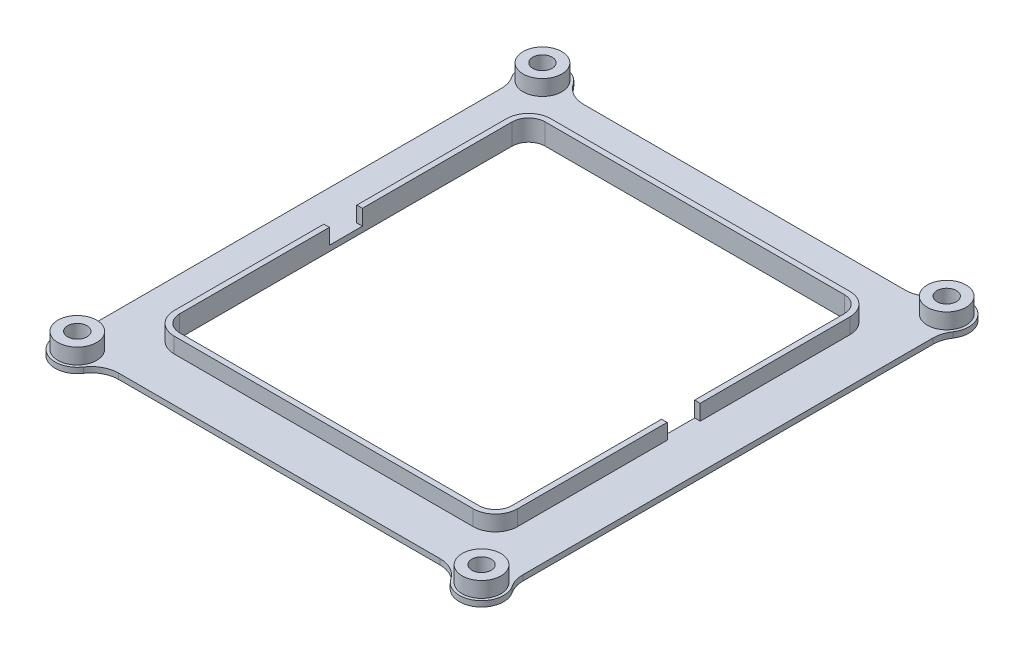
from build123d import *
from build123d.topology import SkipClean

# Parameters (mm, degrees)
FRAMEANDBOLTHOLES_DEPTH       = 3.8
INSIDEFILLET_DEPTH            = 3.8
MIRRORFILLET2_COPY_1_DEPTH    = 3.8
WIRETROUGH_DEPTH              = 1
WIREINSIDEWALL_DEPTH          = 2.8
WIRESPACEMIRROR2_COPY_1_DEPTH = 1
WIRESPACEMIRROR2_COPY_2_DEPTH = 2.8
INNERRING_START               = 1
INNERRING_DEPTH               = 1
REMOVEOUTERRING_START         = -2.8
SKETCH8_W                     = 100
SKETCH8_H                     = 100
SKETCH8_R                     = 3.5
SKETCH8_W_2                   = 62
SKETCH8_H_2                   = 68
REMOVEOUTERRING_DEPTH         = 2.8
BOSS_EXTRUDE2_DEPTH           = 1
MIRROR2_COPY_1_DEPTH          = 1
SKETCH10_W                    = 2.5
SKETCH10_H                    = 78.428011258
SKETCH10_H_2                  = 79.101020514
BOSS_EXTRUDE3_DEPTH           = 1
FILLET1_R                     = 5
SKETCH11_R                    = 3
CUT_EXTRUDE1_DEPTH            = 2.8


with BuildPart() as part:
    # Sketch1 → FrameAndBoltHoles (new body)
    with BuildSketch(Plane(origin=(0, 0, 0), x_dir=(1, 0, 0), z_dir=(0, 1, 0))):
        with BuildLine():
            Line((33, 42), (-33, 42))
            ThreePointArc((-33, 42), (-33.036666571, 41.494706462), (-33.145898034, 41))
            Line((-33.145898034, 41), (33.145898034, 41))
            ThreePointArc((33.145898034, 41), (33.036666571, 41.494706462), (33, 42))
        make_face()
        with BuildLine():
            ThreePointArc((-33.145898034, 41), (-33.036666571, 41.494706462), (-33, 42))
            ThreePointArc((-33, 42), (-38.974873734, 44.474873734), (-36.5, 38.5))
            ThreePointArc((-36.5, 38.5), (-35.994706462, 38.536666571), (-35.5, 38.645898034))
            Line((-35.5, 38.645898034), (-35.5, 40.563859338))
            ThreePointArc((-35.5, 40.563859338), (-38.051209206, 42.810092587), (-34.75, 42))
            ThreePointArc((-34.75, 42), (-34.83030749, 41.475951413), (-35.063859338, 41))
            Line((-35.063859338, 41), (-33.145898034, 41))
        make_face()
        with BuildLine():
            ThreePointArc((-35.5, 38.645898034), (-34.025126266, 39.525126266), (-33.145898034, 41))
            Line((-33.145898034, 41), (-35.063859338, 41))
            ThreePointArc((-35.063859338, 41), (-35.262563133, 40.762563133), (-35.5, 40.563859338))
            Line((-35.5, 40.563859338), (-35.5, 38.645898034))
        make_face()
        with BuildLine():
            ThreePointArc((-35.5, 38.645898034), (-35.994706462, 38.536666571), (-36.5, 38.5))
            Line((-36.5, 38.5), (-36.5, -38.5))
            ThreePointArc((-36.5, -38.5), (-35.994706462, -38.536666571), (-35.5, -38.645898034))
            Line((-35.5, -38.645898034), (-35.5, 38.645898034))
        make_face()
        with BuildLine():
            ThreePointArc((-35.5, -38.645898034), (-35.994706462, -38.536666571), (-36.5, -38.5))
            ThreePointArc((-36.5, -38.5), (-38.974873734, -44.474873734), (-33, -42))
            ThreePointArc((-33, -42), (-33.036666571, -41.494706462), (-33.145898034, -41))
            Line((-33.145898034, -41), (-35.063859338, -41))
            ThreePointArc((-35.063859338, -41), (-34.83030749, -41.475951413), (-34.75, -42))
            ThreePointArc((-34.75, -42), (-38.051209206, -42.810092587), (-35.5, -40.563859338))
            Line((-35.5, -40.563859338), (-35.5, -38.645898034))
        make_face()
        with BuildLine():
            ThreePointArc((-33.145898034, -41), (-34.025126266, -39.525126266), (-35.5, -38.645898034))
            Line((-35.5, -38.645898034), (-35.5, -40.563859338))
            ThreePointArc((-35.5, -40.563859338), (-35.262563133, -40.762563133), (-35.063859338, -41))
            Line((-35.063859338, -41), (-33.145898034, -41))
        make_face()
        with BuildLine():
            ThreePointArc((-33.145898034, -41), (-33.036666571, -41.494706462), (-33, -42))
            Line((-33, -42), (33, -42))
            ThreePointArc((33, -42), (33.036666571, -41.494706462), (33.145898034, -41))
            Line((33.145898034, -41), (-33.145898034, -41))
        make_face()
        with BuildLine():
            ThreePointArc((40, -42), (38.974873734, -39.525126266), (36.5, -38.5))
            ThreePointArc((36.5, -38.5), (35.994706462, -38.536666571), (35.5, -38.645898034))
            Line((35.5, -38.645898034), (35.5, -40.563859338))
            ThreePointArc((35.5, -40.563859338), (37.310092587, -40.448790794), (38.25, -42))
            ThreePointArc((38.25, -42), (35.975951413, -43.66969251), (35.063859338, -41))
            Line((35.063859338, -41), (33.145898034, -41))
            ThreePointArc((33.145898034, -41), (33.036666571, -41.494706462), (33, -42))
            ThreePointArc((33, -42), (36.5, -45.5), (40, -42))
        make_face()
        with BuildLine():
            Line((35.5, -40.563859338), (35.5, -38.645898034))
            ThreePointArc((35.5, -38.645898034), (34.025126266, -39.525126266), (33.145898034, -41))
            Line((33.145898034, -41), (35.063859338, -41))
            ThreePointArc((35.063859338, -41), (35.262563133, -40.762563133), (35.5, -40.563859338))
        make_face()
        with BuildLine():
            Line((36.5, -38.5), (36.5, 38.5))
            ThreePointArc((36.5, 38.5), (35.994706462, 38.536666571), (35.5, 38.645898034))
            Line((35.5, 38.645898034), (35.5, -38.645898034))
            ThreePointArc((35.5, -38.645898034), (35.994706462, -38.536666571), (36.5, -38.5))
        make_face()
        with BuildLine():
            ThreePointArc((40, 42), (36.5, 45.5), (33, 42))
            ThreePointArc((33, 42), (33.036666571, 41.494706462), (33.145898034, 41))
            Line((33.145898034, 41), (35.063859338, 41))
            ThreePointArc((35.063859338, 41), (35.975951413, 43.66969251), (38.25, 42))
            ThreePointArc((38.25, 42), (37.310092587, 40.448790794), (35.5, 40.563859338))
            Line((35.5, 40.563859338), (35.5, 38.645898034))
            ThreePointArc((35.5, 38.645898034), (35.994706462, 38.536666571), (36.5, 38.5))
            ThreePointArc((36.5, 38.5), (38.974873734, 39.525126266), (40, 42))
        make_face()
        with BuildLine():
            Line((35.063859338, 41), (33.145898034, 41))
            ThreePointArc((33.145898034, 41), (34.025126266, 39.525126266), (35.5, 38.645898034))
            Line((35.5, 38.645898034), (35.5, 40.563859338))
            ThreePointArc((35.5, 40.563859338), (35.262563133, 40.762563133), (35.063859338, 41))
        make_face()
    extrude(amount=FRAMEANDBOLTHOLES_DEPTH)

    # Sketch2 → InsideFillet (add)
    with BuildSketch(Plane(origin=(0, 0, 0), x_dir=(1, 0, 0), z_dir=(0, 1, 0))):
        with BuildLine():
            Line((-35.5, 38.645898034), (-35.5, 36.500000047))
            ThreePointArc((-35.5, 36.500000047), (-35.313532909, 37.781964835), (-34.769584986, 38.957687741))
            ThreePointArc((-34.769584986, 38.957687741), (-35.125920402, 38.781008658), (-35.5, 38.645898034))
        make_face()
    insidefillet = extrude(amount=INSIDEFILLET_DEPTH)

    # MirrorFillet: InsideFillet across plane
    add(insidefillet.mirror(Plane(origin=(0, 0, 0), x_dir=(0, 0, 1), z_dir=(1, 0, 0))))

    # MirrorFillet2: InsideFillet across plane
    add(insidefillet.mirror(Plane.XY))

    # MirrorFillet2 copy 1 sketch → MirrorFillet2 copy 1 (add)
    with BuildSketch(Plane(origin=(0, 0, 0), x_dir=(-1, 0, 0), z_dir=(0, 1, 0))):
        with BuildLine():
            Line((-35.5, 38.645898034), (-35.5, 36.500000047))
            ThreePointArc((-35.5, 36.500000047), (-35.313532909, 37.781964835), (-34.769584986, 38.957687741))
            ThreePointArc((-34.769584986, 38.957687741), (-35.125920402, 38.781008658), (-35.5, 38.645898034))
        make_face()
    extrude(amount=MIRRORFILLET2_COPY_1_DEPTH)

    # Sketch3 → WireTrough (add)
    with BuildSketch(Plane(origin=(0, 0, 0), x_dir=(1, 0, 0), z_dir=(0, 1, 0))):
        with BuildLine():
            Line((-27, 41), (-27, 34))
            ThreePointArc((-27, 34), (-26.54814994, 33.974397001), (-26.102084238, 33.897915762))
            Line((-26.102084238, 33.897915762), (-19, 41))
            Line((-19, 41), (-27, 41))
        make_face()
        with BuildLine():
            ThreePointArc((-31, 30), (-29.828427125, 32.828427125), (-27, 34))
            Line((-27, 34), (-27, 41))
            Line((-27, 41), (-31, 41))
            ThreePointArc((-31, 41), (-34.181980515, 39.681980515), (-35.5, 36.5))
            Line((-35.5, 36.5), (-35.5, 30))
            Line((-35.5, 30), (-31, 30))
        make_face()
        with BuildLine():
            ThreePointArc((-30.897915762, 29.102084238), (-30.974397001, 29.54814994), (-31, 30))
            Line((-31, 30), (-35.5, 30))
            Line((-35.5, 30), (-35.5, 24.5))
            Line((-35.5, 24.5), (-30.897915762, 29.102084238))
        make_face()
        with BuildLine():
            Line((-27, 34), (-27, 33))
            Line((-27, 33), (-26.102084238, 33.897915762))
            ThreePointArc((-26.102084238, 33.897915762), (-26.54814994, 33.974397001), (-27, 34))
        make_face()
        with BuildLine():
            ThreePointArc((-30, 30), (-29.121320344, 32.121320344), (-27, 33))
            Line((-27, 33), (-27, 34))
            ThreePointArc((-27, 34), (-29.828427125, 32.828427125), (-31, 30))
            Line((-31, 30), (-30, 30))
        make_face()
        with BuildLine():
            Line((-30.897915762, 29.102084238), (-30, 30))
            Line((-30, 30), (-31, 30))
            ThreePointArc((-31, 30), (-30.974397001, 29.54814994), (-30.897915762, 29.102084238))
        make_face()
    wiretrough = extrude(amount=WIRETROUGH_DEPTH)

    # Sketch4 → WireInsideWall (add)
    with BuildSketch(Plane(origin=(0, 1, 0), x_dir=(1, 0, 0), z_dir=(0, 1, 0))):
        with BuildLine():
            ThreePointArc((-30, 30), (-29.121320344, 32.121320344), (-27, 33))
            Line((-27, 33), (-26.102084238, 33.897915762))
            ThreePointArc((-26.102084238, 33.897915762), (-26.54814994, 33.974397001), (-27, 34))
            ThreePointArc((-27, 34), (-29.828427125, 32.828427125), (-31, 30))
            ThreePointArc((-31, 30), (-30.974397001, 29.54814994), (-30.897915762, 29.102084238))
            Line((-30.897915762, 29.102084238), (-30, 30))
        make_face()
        with BuildLine():
            Line((-26, 34), (-26.102084238, 33.897915762))
            ThreePointArc((-26.102084238, 33.897915762), (-25.172171436, 33.557954854), (-24.354248689, 33))
            Line((-24.354248689, 33), (0, 33))
            Line((0, 33), (0, 34))
            Line((0, 34), (-26, 34))
        make_face()
        with BuildLine():
            Line((-26.102084238, 33.897915762), (-27, 33))
            Line((-27, 33), (-24.354248689, 33))
            ThreePointArc((-24.354248689, 33), (-25.172171436, 33.557954854), (-26.102084238, 33.897915762))
        make_face()
        with BuildLine():
            Line((-30, 27.354248689), (-30, 30))
            Line((-30, 30), (-30.897915762, 29.102084238))
            ThreePointArc((-30.897915762, 29.102084238), (-30.557954854, 28.172171436), (-30, 27.354248689))
        make_face()
        with BuildLine():
            ThreePointArc((-30, 27.354248689), (-30.557954854, 28.172171436), (-30.897915762, 29.102084238))
            Line((-30.897915762, 29.102084238), (-31, 29))
            Line((-31, 29), (-31, 0))
            Line((-31, 0), (-30, 0))
            Line((-30, 0), (-30, 27.354248689))
        make_face()
        with BuildLine():
            ThreePointArc((-27, 34), (-26.54814994, 33.974397001), (-26.102084238, 33.897915762))
            Line((-26.102084238, 33.897915762), (-26, 34))
            Line((-26, 34), (-27, 34))
        make_face()
        with BuildLine():
            Line((-31, 29), (-30.897915762, 29.102084238))
            ThreePointArc((-30.897915762, 29.102084238), (-30.974397001, 29.54814994), (-31, 30))
            Line((-31, 30), (-31, 29))
        make_face()
    wireinsidewall = extrude(amount=WIREINSIDEWALL_DEPTH)

    # WireSpaceMirror: WireTrough, WireInsideWall across plane
    add(wiretrough.mirror(Plane(origin=(0, 0, 0), x_dir=(0, 0, 1), z_dir=(1, 0, 0))))
    add(wireinsidewall.mirror(Plane(origin=(0, 0, 0), x_dir=(0, 0, 1), z_dir=(1, 0, 0))))

    # WireSpaceMirror2: WireTrough, WireInsideWall across plane
    add(wiretrough.mirror(Plane.XY))
    add(wireinsidewall.mirror(Plane.XY))

    # WireSpaceMirror2 copy 1 sketch → WireSpaceMirror2 copy 1 (add)
    with BuildSketch(Plane(origin=(0, 0, 0), x_dir=(-1, 0, 0), z_dir=(0, 1, 0))):
        with BuildLine():
            Line((-27, 41), (-27, 34))
            ThreePointArc((-27, 34), (-26.54814994, 33.974397001), (-26.102084238, 33.897915762))
            Line((-26.102084238, 33.897915762), (-19, 41))
            Line((-19, 41), (-27, 41))
        make_face()
        with BuildLine():
            ThreePointArc((-31, 30), (-29.828427125, 32.828427125), (-27, 34))
            Line((-27, 34), (-27, 41))
            Line((-27, 41), (-31, 41))
            ThreePointArc((-31, 41), (-34.181980515, 39.681980515), (-35.5, 36.5))
            Line((-35.5, 36.5), (-35.5, 30))
            Line((-35.5, 30), (-31, 30))
        make_face()
        with BuildLine():
            ThreePointArc((-30.897915762, 29.102084238), (-30.974397001, 29.54814994), (-31, 30))
            Line((-31, 30), (-35.5, 30))
            Line((-35.5, 30), (-35.5, 24.5))
            Line((-35.5, 24.5), (-30.897915762, 29.102084238))
        make_face()
        with BuildLine():
            Line((-27, 34), (-27, 33))
            Line((-27, 33), (-26.102084238, 33.897915762))
            ThreePointArc((-26.102084238, 33.897915762), (-26.54814994, 33.974397001), (-27, 34))
        make_face()
        with BuildLine():
            ThreePointArc((-30, 30), (-29.121320344, 32.121320344), (-27, 33))
            Line((-27, 33), (-27, 34))
            ThreePointArc((-27, 34), (-29.828427125, 32.828427125), (-31, 30))
            Line((-31, 30), (-30, 30))
        make_face()
        with BuildLine():
            Line((-30.897915762, 29.102084238), (-30, 30))
            Line((-30, 30), (-31, 30))
            ThreePointArc((-31, 30), (-30.974397001, 29.54814994), (-30.897915762, 29.102084238))
        make_face()
    extrude(amount=WIRESPACEMIRROR2_COPY_1_DEPTH)

    # WireSpaceMirror2 copy 2 sketch → WireSpaceMirror2 copy 2 (add)
    with BuildSketch(Plane(origin=(0, 1, 0), x_dir=(-1, 0, 0), z_dir=(0, 1, 0))):
        with BuildLine():
            ThreePointArc((-30, 30), (-29.121320344, 32.121320344), (-27, 33))
            Line((-27, 33), (-26.102084238, 33.897915762))
            ThreePointArc((-26.102084238, 33.897915762), (-26.54814994, 33.974397001), (-27, 34))
            ThreePointArc((-27, 34), (-29.828427125, 32.828427125), (-31, 30))
            ThreePointArc((-31, 30), (-30.974397001, 29.54814994), (-30.897915762, 29.102084238))
            Line((-30.897915762, 29.102084238), (-30, 30))
        make_face()
        with BuildLine():
            Line((-26, 34), (-26.102084238, 33.897915762))
            ThreePointArc((-26.102084238, 33.897915762), (-25.172171436, 33.557954854), (-24.354248689, 33))
            Line((-24.354248689, 33), (0, 33))
            Line((0, 33), (0, 34))
            Line((0, 34), (-26, 34))
        make_face()
        with BuildLine():
            Line((-26.102084238, 33.897915762), (-27, 33))
            Line((-27, 33), (-24.354248689, 33))
            ThreePointArc((-24.354248689, 33), (-25.172171436, 33.557954854), (-26.102084238, 33.897915762))
        make_face()
        with BuildLine():
            Line((-30, 27.354248689), (-30, 30))
            Line((-30, 30), (-30.897915762, 29.102084238))
            ThreePointArc((-30.897915762, 29.102084238), (-30.557954854, 28.172171436), (-30, 27.354248689))
        make_face()
        with BuildLine():
            ThreePointArc((-30, 27.354248689), (-30.557954854, 28.172171436), (-30.897915762, 29.102084238))
            Line((-30.897915762, 29.102084238), (-31, 29))
            Line((-31, 29), (-31, 0))
            Line((-31, 0), (-30, 0))
            Line((-30, 0), (-30, 27.354248689))
        make_face()
        with BuildLine():
            ThreePointArc((-27, 34), (-26.54814994, 33.974397001), (-26.102084238, 33.897915762))
            Line((-26.102084238, 33.897915762), (-26, 34))
            Line((-26, 34), (-27, 34))
        make_face()
        with BuildLine():
            Line((-31, 29), (-30.897915762, 29.102084238))
            ThreePointArc((-30.897915762, 29.102084238), (-30.974397001, 29.54814994), (-31, 30))
            Line((-31, 30), (-31, 29))
        make_face()
    extrude(amount=WIRESPACEMIRROR2_COPY_2_DEPTH)

    # Sketch7 → InnerRing (add)
    # profile 1 of 2: a face of its own
    with SkipClean():  # the faces are left unmerged after this step: merging them gives an invalid solid
        with BuildSketch(Plane.XZ.offset(-1).offset(INNERRING_START)):
            with BuildLine():
                Line((35.063859338, 41), (-35.063859338, 41))
                ThreePointArc((-35.063859338, 41), (-35.262563133, 40.762563133), (-35.5, 40.563859338))
                Line((-35.5, 40.563859338), (-35.5, -40.563859338))
                ThreePointArc((-35.5, -40.563859338), (-35.262563133, -40.762563133), (-35.063859338, -41))
                Line((-35.063859338, -41), (35.063859338, -41))
                ThreePointArc((35.063859338, -41), (35.262563133, -40.762563133), (35.5, -40.563859338))
                Line((35.5, -40.563859338), (35.5, 40.563859338))
                ThreePointArc((35.5, 40.563859338), (35.262563133, 40.762563133), (35.063859338, 41))
            make_face()
            Polygon((-30, -33), (-30, 33), (30, 33), (30, -33), (27, -33), (26, -34), (-26, -34), (-27, -33), align=None, mode=Mode.SUBTRACT)
        # profile 2 of 2: a face of its own
        with BuildSketch(Plane.XZ.offset(-1).offset(INNERRING_START)):
            Polygon((26, -34), (27, -33), (-27, -33), (-26, -34), align=None)
        extrude(amount=-INNERRING_DEPTH)

    # Sketch8 → RemoveOuterRing (cut)
    with SkipClean():  # the faces are left unmerged after this step: merging them gives an invalid solid
        with BuildSketch(Plane(origin=(0, 3.8, 0), x_dir=(1, 0, 0), z_dir=(0, 1, 0)).offset(REMOVEOUTERRING_START)):
            Rectangle(SKETCH8_W, SKETCH8_H)
            with Locations(Location((-36.5, 42, 0), (0, 0, 270))):
                Circle(SKETCH8_R, mode=Mode.SUBTRACT)
            with Locations(Location((36.5, 42, 0), (0, 0, 270))):
                Circle(SKETCH8_R, mode=Mode.SUBTRACT)
            with Locations(Location((36.5, -42, 0), (0, 0, 90))):
                Circle(SKETCH8_R, mode=Mode.SUBTRACT)
            with Locations(Location((-36.5, -42, 0), (0, 0, 90))):
                Circle(SKETCH8_R, mode=Mode.SUBTRACT)
            Rectangle(SKETCH8_W_2, SKETCH8_H_2, mode=Mode.SUBTRACT)
        extrude(amount=REMOVEOUTERRING_DEPTH, mode=Mode.SUBTRACT)

    # Sketch9 → Boss-Extrude2 (add)
    with SkipClean():  # the faces are left unmerged after this step: merging them gives an invalid solid
        with BuildSketch(Plane.XZ):
            with BuildLine():
                ThreePointArc((-36.5, -46), (-33.671572875, -44.828427125), (-32.5, -42))
                Line((-32.5, -42), (-33, -42))
                ThreePointArc((-33, -42), (-38.974873734, -44.474873734), (-36.5, -38.5))
                Line((-36.5, -38.5), (-36.5, -38))
                ThreePointArc((-36.5, -38), (-39.328427125, -39.171572875), (-40.5, -42))
                ThreePointArc((-40.5, -42), (-39.328427125, -44.828427125), (-36.5, -46))
            make_face()
        boss_extrude2 = extrude(amount=-BOSS_EXTRUDE2_DEPTH)

    # Mirror1: Boss-Extrude2 across plane
    with SkipClean():  # the faces are left unmerged after this step: merging them gives an invalid solid
        add(boss_extrude2.mirror(Plane(origin=(0, 0, 0), x_dir=(0, 0, 1), z_dir=(1, 0, 0))))

    # Mirror2: Boss-Extrude2 across plane
    with SkipClean():  # the faces are left unmerged after this step: merging them gives an invalid solid
        add(boss_extrude2.mirror(Plane.XY))

    # Mirror2 copy 1 sketch → Mirror2 copy 1 (add)
    with SkipClean():  # the faces are left unmerged after this step: merging them gives an invalid solid
        with BuildSketch(Plane(origin=(0, 0, 0), x_dir=(-1, 0, 0), z_dir=(0, -1, 0))):
            with BuildLine():
                ThreePointArc((-36.5, -46), (-33.671572875, -44.828427125), (-32.5, -42))
                Line((-32.5, -42), (-33, -42))
                ThreePointArc((-33, -42), (-38.974873734, -44.474873734), (-36.5, -38.5))
                Line((-36.5, -38.5), (-36.5, -38))
                ThreePointArc((-36.5, -38), (-39.328427125, -39.171572875), (-40.5, -42))
                ThreePointArc((-40.5, -42), (-39.328427125, -44.828427125), (-36.5, -46))
            make_face()
        extrude(amount=-MIRROR2_COPY_1_DEPTH)

    # Sketch10 → Boss-Extrude3 (add)
    with SkipClean():  # the faces are left unmerged after this step: merging them gives an invalid solid
        with BuildSketch(Plane(origin=(0, 1, 0), x_dir=(1, 0, 0), z_dir=(0, 1, 0))):
            with Locations((37.75, 0.336504628)):
                Rectangle(SKETCH10_W, SKETCH10_H)
            with Locations((-37.75, 0)):
                Rectangle(SKETCH10_W, SKETCH10_H_2)
        extrude(amount=-BOSS_EXTRUDE3_DEPTH)

    # Fillet1
    fillet1_edges = [part.edges().sort_by_distance(p)[0] for p in [
        (-32.5, 0.5, -42),
        (32.5, 0.5, -42),
        (32.5, 0.5, 42),
        (-32.5, 0.5, 42),
        (39, 0.5, -38.877501001),
        (39, 0.5, 38.877501001),
        (-39, 0.5, 38.877501001),
        (-39, 0.5, -38.877501001),
    ]]
    fillet(fillet1_edges, radius=FILLET1_R)

    # Sketch11 → Cut-Extrude1 (cut)
    with SkipClean():  # the faces are left unmerged after this step: merging them gives an invalid solid
        with BuildSketch(Plane(origin=(0, 3.8, 0), x_dir=(1, 0, 0), z_dir=(0, 1, 0))):
            with Locations((30.5, 0)):
                Circle(SKETCH11_R)
            with Locations((-30.5, 0)):
                Circle(SKETCH11_R)
        extrude(amount=-CUT_EXTRUDE1_DEPTH, mode=Mode.SUBTRACT)


solid = part.part
